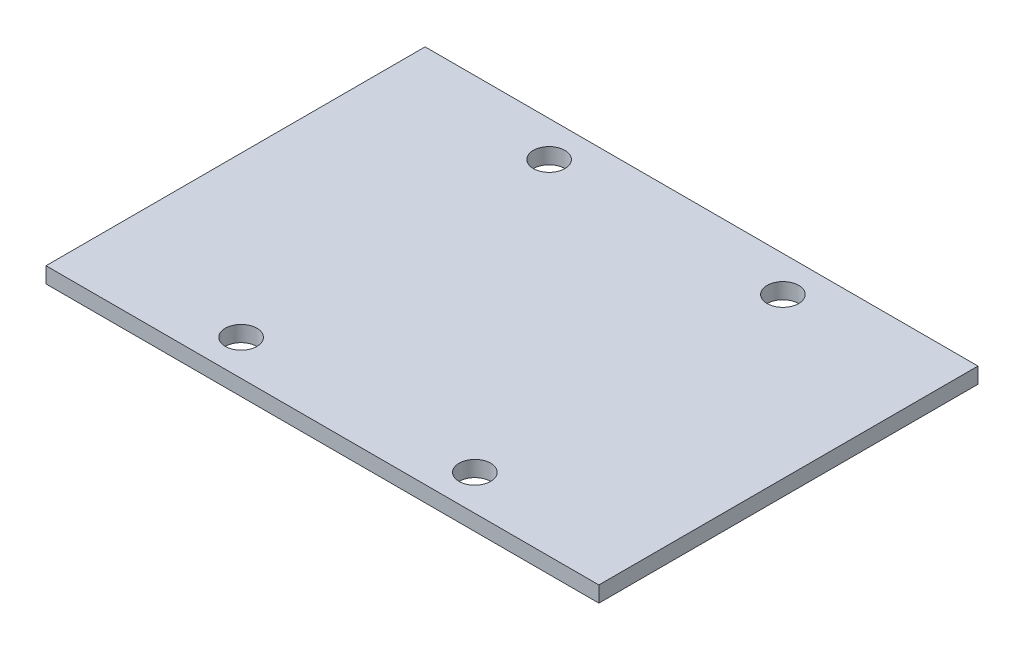
from build123d import *

# Parameters (mm, degrees)
SKETCH_1_R      = 2
EXTRUDE_1_DEPTH = 2


with BuildPart() as part:
    # 草图1 → 凸台-拉伸1 (new body)
    with BuildSketch(Plane(origin=(0, 0, 0), x_dir=(1, 0, 0), z_dir=(0, 1, 0))):
        Polygon((20, -12), (-20, -12), (-35, -12), (-35, 36), (-20, 36), (20, 36), (35, 36), (35, -12), align=None)
        with Locations((-14.8, -7.5)):
            Circle(SKETCH_1_R, mode=Mode.SUBTRACT)
        with Locations((14.8, -7.5)):
            Circle(SKETCH_1_R, mode=Mode.SUBTRACT)
        with Locations((14.8, 31.5)):
            Circle(SKETCH_1_R, mode=Mode.SUBTRACT)
        with Locations((-14.8, 31.5)):
            Circle(SKETCH_1_R, mode=Mode.SUBTRACT)
    extrude(amount=EXTRUDE_1_DEPTH)


solid = part.part
